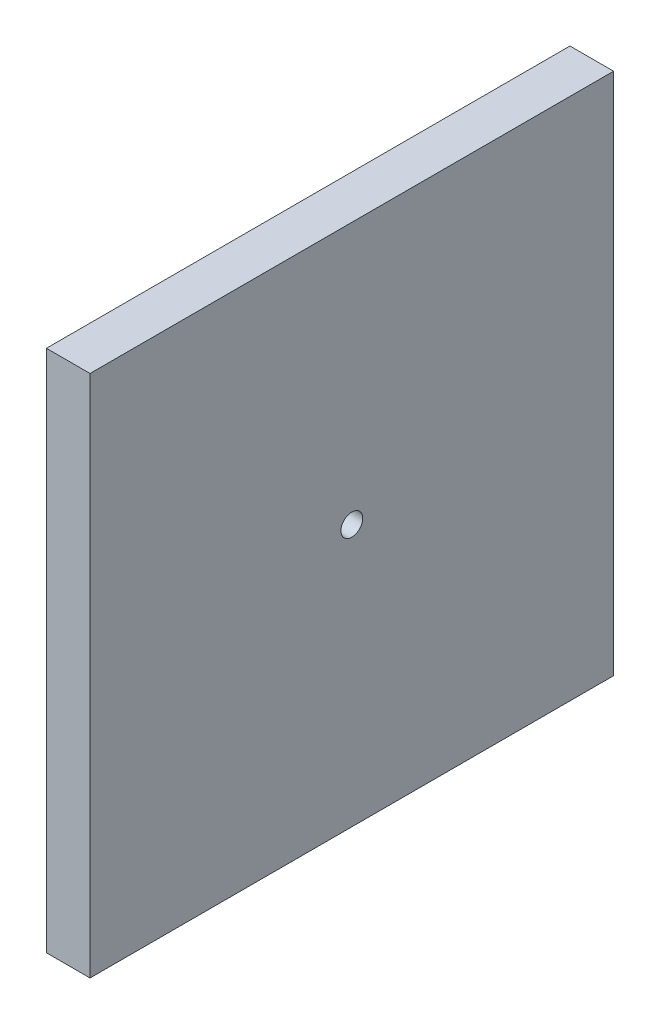
from build123d import *

# Parameters (mm, degrees)
SKETCH1_W               = 304.8
SKETCH1_H               = 304.8
BOSS_EXTRUDE1_DEPTH     = 12.7
CUT_EXTRUDE1_DEPTH      = 216.9
CUT_EXTRUDE1_DEPTH_BACK = 216.9
SKETCH2_R               = 6.35


with BuildPart() as part:
    # Sketch1 → Boss-Extrude1 (new, symmetric)
    with BuildSketch(Plane(origin=(0, 0, 0), x_dir=(0, 0, -1), z_dir=(1, 0, 0))):
        Rectangle(SKETCH1_W, SKETCH1_H)
    extrude(amount=BOSS_EXTRUDE1_DEPTH, both=True)

    # Sketch2 → Cut-Extrude1 (cut, two sides: drawn at the far end of the back side and taken through both)
    with BuildSketch(Plane(origin=(0, 0, 0), x_dir=(0, 0, -1), z_dir=(1, 0, 0)).offset(-CUT_EXTRUDE1_DEPTH_BACK)):
        Circle(SKETCH2_R)
    extrude(amount=CUT_EXTRUDE1_DEPTH + CUT_EXTRUDE1_DEPTH_BACK, mode=Mode.SUBTRACT)


solid = part.part
